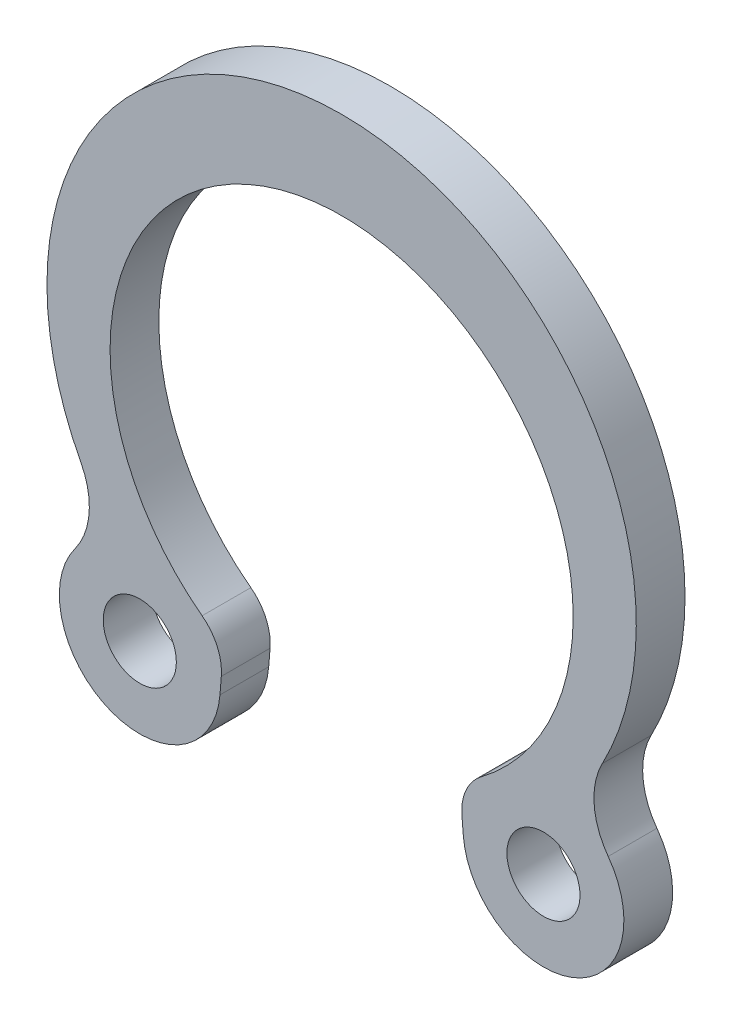
from build123d import *

# Parameters (mm, degrees)
SKETCH_2_R      = 0.75
EXTRUDE_1_DEPTH = 1


with BuildPart() as part:
    # Эскиз2 → Бобышка-Вытянуть1 (new body)
    with BuildSketch(Plane.XY):
        with BuildLine():
            Line((1e-09, 4.75), (0, 6.55))
            ThreePointArc((0, 6.55), (-5.174962188, 3.628926318), (-5.348211601, -2.311013895))
            ThreePointArc((-5.348211601, -2.311013895), (-5.179687707, -3.123034993), (-5.468378103, -3.900490086))
            ThreePointArc((-5.468378103, -3.900490086), (-4.719418002, -6.425234093), (-2.496065251, -5.013860266))
            Line((-2.496065251, -5.013860266), (-2.468043041, -4.670176577))
            ThreePointArc((-2.468043041, -4.670176577), (-2.552204681, -4.179903536), (-2.862172849, -3.790839825))
            ThreePointArc((-2.862172849, -3.790839825), (-4.503831101, 1.50930627), (1e-09, 4.75))
        make_face()
        with Locations((-4.140632757, -4.880077906)):
            Circle(SKETCH_2_R, mode=Mode.SUBTRACT)
    extrude(amount=EXTRUDE_1_DEPTH)

    # Зеркальное отражение1: part across plane


with BuildPart() as part_1:
    add(part.part)
    add(part.part.mirror(Plane(origin=(1e-09, 4.75, 1), x_dir=(0, 0, 1), z_dir=(-1, 0, 0))))


solid = part_1.part
